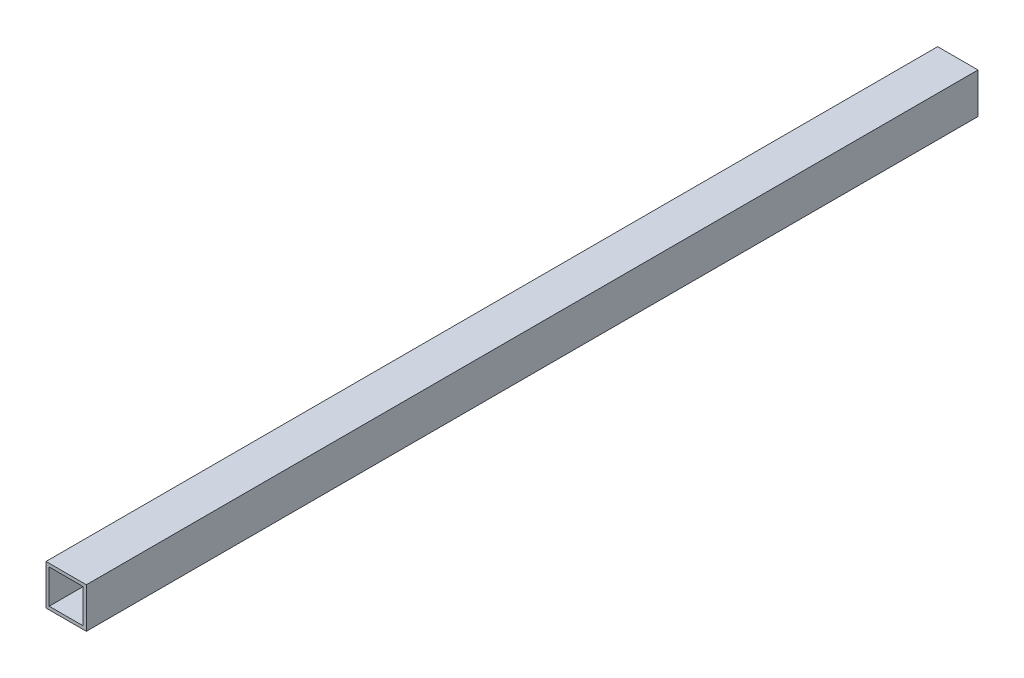
from build123d import *

# Parameters (mm, degrees)
SKETCH1_W           = 25.4
SKETCH1_H           = 25.4
SKETCH1_W_2         = 21.4
SKETCH1_H_2         = 21.4
BOSS_EXTRUDE1_DEPTH = 561.2


with BuildPart() as part:
    # Sketch1 → Boss-Extrude1 (new body)
    with BuildSketch(Plane.XY):
        Rectangle(SKETCH1_W, SKETCH1_H)
        Rectangle(SKETCH1_W_2, SKETCH1_H_2, mode=Mode.SUBTRACT)
    extrude(amount=BOSS_EXTRUDE1_DEPTH)


solid = part.part
